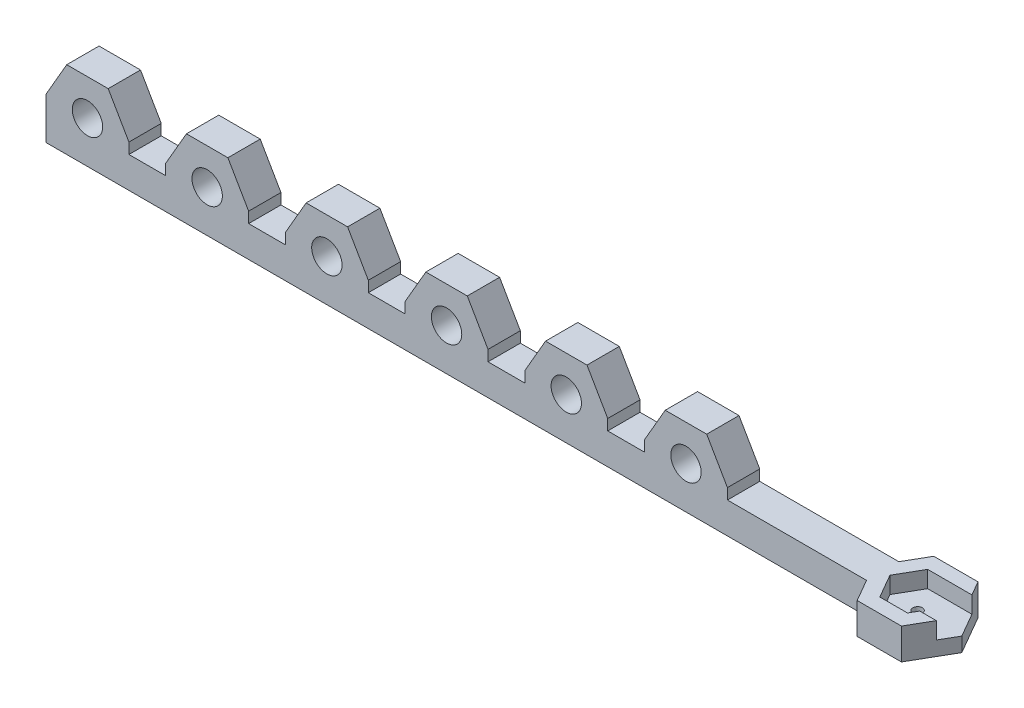
from build123d import *

# Parameters (mm, degrees)
SKETCH1_W           = 175
SKETCH1_H           = 6.75
BOSS_EXTRUDE1_DEPTH = 6.5
SKETCH2_W           = 10
SKETCH2_H           = 6.75
BOSS_EXTRUDE2_DEPTH = 7.5
SKETCH5_R           = 3.175
CUT_EXTRUDE2_DEPTH  = 10
LPATTERN1_COUNT     = 6
LPATTERN1_PITCH     = 25
SKETCH6_R           = 3.175
BOSS_EXTRUDE4_DEPTH = 6.75
LPATTERN2_COUNT     = 6
LPATTERN2_PITCH     = 25
BOSS_EXTRUDE5_DEPTH = 6.5
BOSS_EXTRUDE6_DEPTH = 3
SKETCH10_R          = 2.575
CUT_EXTRUDE4_DEPTH  = 2
CUT_EXTRUDE5_DEPTH  = 18
SKETCH12_R          = 1
CUT_EXTRUDE6_DEPTH  = 10


with BuildPart() as part:
    # Sketch1 → Boss-Extrude1 (new body)
    with BuildSketch(Plane(origin=(0, 0, 0), x_dir=(1, 0, 0), z_dir=(0, 1, 0))):
        with Locations((87.5, -3.375)):
            Rectangle(SKETCH1_W, SKETCH1_H)
    extrude(amount=BOSS_EXTRUDE1_DEPTH)

    # Sketch2 → Boss-Extrude2 (add)
    with BuildSketch(Plane(origin=(0, 6.5, 0), x_dir=(1, 0, 0), z_dir=(0, 1, 0))):
        with Locations((5, -3.375)):
            Rectangle(SKETCH2_W, SKETCH2_H)
    boss_extrude2 = extrude(amount=BOSS_EXTRUDE2_DEPTH)

    # Sketch5 → Cut-Extrude2 (cut)
    with BuildSketch(Plane.XY.offset(6.75)):
        with Locations((5, 8.75)):
            Circle(SKETCH5_R)
    cut_extrude2 = extrude(amount=-CUT_EXTRUDE2_DEPTH, mode=Mode.SUBTRACT)

    # LPattern1: Boss-Extrude2, Cut-Extrude2 ×6
    with Locations(*[(i * LPATTERN1_PITCH, 0, 0) for i in range(1, LPATTERN1_COUNT)]):
        add(boss_extrude2)
        add(cut_extrude2, mode=Mode.SUBTRACT)

    # Sketch6 → Boss-Extrude4 (add)
    with BuildSketch(Plane.XY.offset(6.75)):
        Polygon((138.660254038, 8.75), (138.660254038, 0), (121.339745962, 0), (121.339745962, 8.75), (125.669872981, 16.25), (134.330127019, 16.25), align=None)
        with Locations((130, 8.75)):
            Circle(SKETCH6_R, mode=Mode.SUBTRACT)
    boss_extrude4 = extrude(amount=-BOSS_EXTRUDE4_DEPTH)

    # LPattern2: Boss-Extrude4 ×6
    with Locations(*[(-i * LPATTERN2_PITCH, 0, 0) for i in range(1, LPATTERN2_COUNT)]):
        add(boss_extrude4)

    # Sketch7 → Boss-Extrude5 (add)
    with BuildSketch(Plane(origin=(0, 6.5, 0), x_dir=(1, 0, 0), z_dir=(0, 1, 0))):
        Polygon((172.113248654, -8.375), (177.886751346, -8.375), (178.824945533, -6.75), (182.289047149, -6.75), (179.618802154, -11.375), (170.381197846, -11.375), (165.762395693, -3.375), (170.381197846, 4.625), (179.618802154, 4.625), (181.350852961, 1.625), (177.886751346, 1.625), (172.113248654, 1.625), (169.226497308, -3.375), align=None)
    extrude(amount=-BOSS_EXTRUDE5_DEPTH)

    # Sketch9 → Boss-Extrude6 (add)
    with BuildSketch(Plane(origin=(0, 0, 0), x_dir=(-1, 0, 0), z_dir=(0, -1, 0))):
        Polygon((-169.226497308, -3.375), (-172.113248654, 1.625), (-177.886751346, 1.625), (-181.350852961, 1.625), (-184.237604307, -3.375), (-182.289047149, -6.75), (-178.824945533, -6.75), (-177.886751346, -8.375), (-172.113248654, -8.375), align=None)
    extrude(amount=-BOSS_EXTRUDE6_DEPTH)

    # Sketch10 → Cut-Extrude4 (cut)
    with BuildSketch(Plane(origin=(0, 0, 0), x_dir=(-1, 0, 0), z_dir=(0, -1, 0))):
        with Locations((-175, -3.375)):
            Circle(SKETCH10_R)
    extrude(amount=-CUT_EXTRUDE4_DEPTH, mode=Mode.SUBTRACT)

    # Sketch11 → Cut-Extrude5 (cut)
    with BuildSketch(Plane(origin=(0, 3, 0), x_dir=(1, 0, 0), z_dir=(0, 1, 0))):
        Polygon((180.773502692, -3.375), (177.886751346, 1.625), (172.113248654, 1.625), (169.226497308, -3.375), (172.113248654, -8.375), (177.886751346, -8.375), align=None)
    extrude(amount=CUT_EXTRUDE5_DEPTH, mode=Mode.SUBTRACT)

    # Sketch12 → Cut-Extrude6 (cut)
    with BuildSketch(Plane(origin=(0, 3, 0), x_dir=(1, 0, 0), z_dir=(0, 1, 0))):
        with Locations((175, -3.375)):
            Circle(SKETCH12_R)
    extrude(amount=-CUT_EXTRUDE6_DEPTH, mode=Mode.SUBTRACT)


solid = part.part
